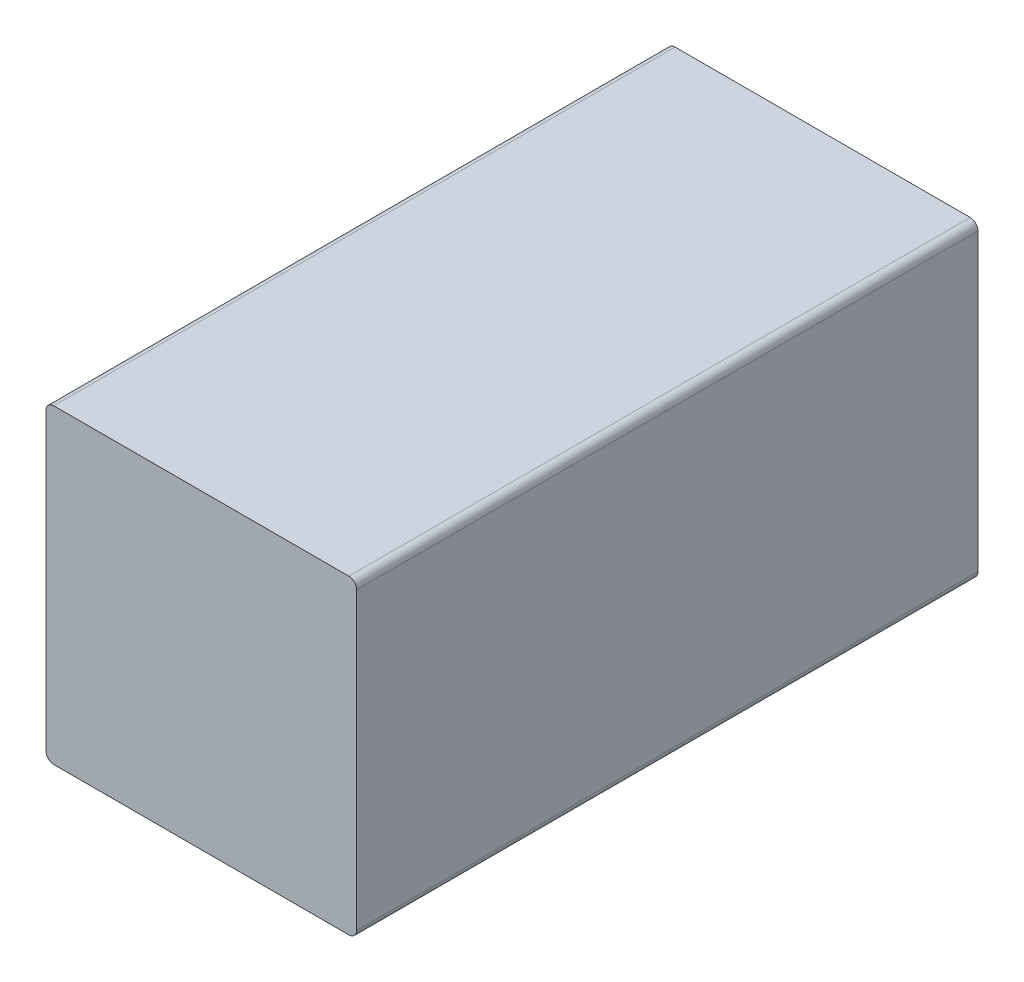
from build123d import *

# Parameters (mm, degrees)
BOSS_EXTRUDE1_START = -4.7625
SKETCH3_W           = 4.7625
SKETCH3_H           = 4.7625
BOSS_EXTRUDE1_DEPTH = 9.525
FILLET1_R           = 0.1190625


with BuildPart() as part:
    # Sketch3 → Boss-Extrude1 (new body)
    with BuildSketch(Plane.XY.offset(BOSS_EXTRUDE1_START)):
        Rectangle(SKETCH3_W, SKETCH3_H)
    extrude(amount=BOSS_EXTRUDE1_DEPTH)

    # Fillet1
    fillet1_edges = [part.edges().sort_by_distance(p)[0] for p in [
        (-2.38125, 2.38125, 0),
        (2.38125, 2.38125, 0),
        (2.38125, -2.38125, 0),
        (-2.38125, -2.38125, 0),
    ]]
    fillet(fillet1_edges, radius=FILLET1_R)


solid = part.part
